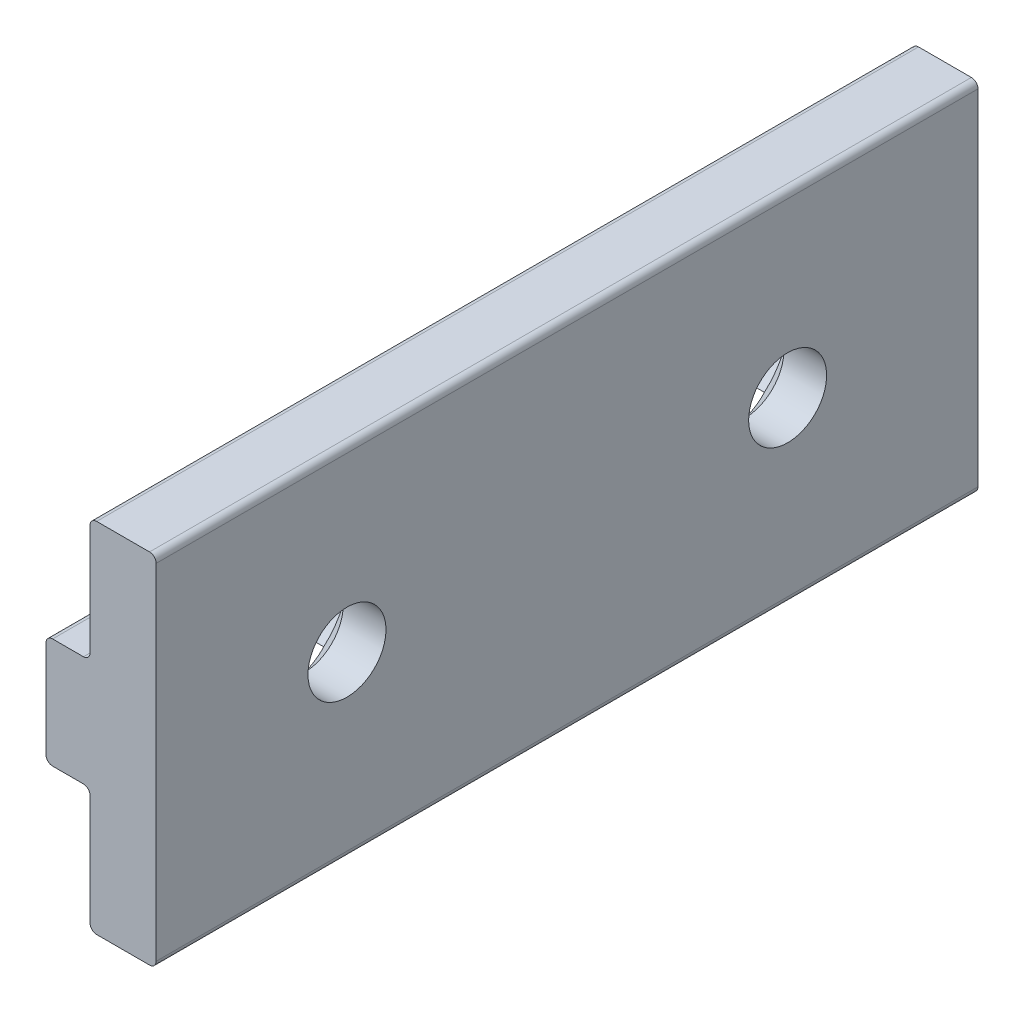
from build123d import *

# Parameters (mm, degrees)
EXTRUDE1_DEPTH                            = 47.371
SKETCH2_R                                 = 1.3843
CUT_EXTRUDE1_DEPTH                        = 7.35
CSK_FOR_8_FLAT_HEAD_MACHINE_SCREW_2_COUNT = 2
CSK_FOR_8_FLAT_HEAD_MACHINE_SCREW_2_PITCH = 25.4


with BuildPart() as part:
    # Sketch1 → Extrude1 (new body)
    with BuildSketch(Plane.XY):
        with BuildLine():
            Line((761.528249985, 570.229723122), (761.528249985, 550.366923122))
            ThreePointArc((761.528249985, 550.366923122), (761.416657669, 550.097515438), (761.147249985, 549.985923122))
            Line((761.147249985, 549.985923122), (758.099249985, 549.985923122))
            ThreePointArc((758.099249985, 549.985923122), (757.829842301, 550.097515438), (757.718249985, 550.366923122))
            Line((757.718249985, 550.366923122), (757.718249985, 556.742323122))
            ThreePointArc((757.718249985, 556.742323122), (757.606657669, 557.011730805), (757.337249985, 557.123323122))
            Line((757.337249985, 557.123323122), (755.559249985, 557.123323122))
            ThreePointArc((755.559249985, 557.123323122), (755.289842301, 557.234915438), (755.178249985, 557.504323122))
            Line((755.178249985, 557.504323122), (755.178249985, 563.092323122))
            ThreePointArc((755.178249985, 563.092323122), (755.289842301, 563.361730805), (755.559249985, 563.473323122))
            Line((755.559249985, 563.473323122), (757.337249985, 563.473323122))
            ThreePointArc((757.337249985, 563.473323122), (757.606657669, 563.584915438), (757.718249985, 563.854323122))
            Line((757.718249985, 563.854323122), (757.718249985, 570.229723122))
            ThreePointArc((757.718249985, 570.229723122), (757.829842301, 570.499130805), (758.099249985, 570.610723122))
            Line((758.099249985, 570.610723122), (761.147249985, 570.610723122))
            ThreePointArc((761.147249985, 570.610723122), (761.416657669, 570.499130805), (761.528249985, 570.229723122))
        make_face()
    extrude(amount=EXTRUDE1_DEPTH)

    # Sketch2 → Cut-Extrude1 (cut, through all)
    with BuildSketch(Plane.ZY.offset(-755.178249985)):
        with Locations((10.9728, 560.298323122)):
            Circle(SKETCH2_R)
        with Locations((36.3728, 560.298323122)):
            Circle(SKETCH2_R)
    extrude(amount=-CUT_EXTRUDE1_DEPTH, mode=Mode.SUBTRACT)

    # Sketch3 → CSK for #8 Flat Head Machine Screw (100)1 (revolve, cut)
    with BuildSketch(Plane(origin=(755.178249985, 560.298323122, 10.9728), x_dir=(0, 0, 1), z_dir=(0, 1, 0))):
        Polygon((0, 0), (0, 6.35), (2.2479, 6.35), (2.2479, 3.886967624), (4.2164, 2.2352), (4.2164, 0), align=None)
    csk_for_8_flat_head_machine_screw_100 = revolve(axis=Axis((748.828249985, 560.298323122, 10.9728), (1, 0, 0)), mode=Mode.SUBTRACT)

    # CSK for _8 Flat Head Machine Screw _ 2: CSK for #8 Flat Head Machine Screw (100)1 ×2
    with Locations(*[(0, 0, i * CSK_FOR_8_FLAT_HEAD_MACHINE_SCREW_2_PITCH) for i in range(1, CSK_FOR_8_FLAT_HEAD_MACHINE_SCREW_2_COUNT)]):
        add(csk_for_8_flat_head_machine_screw_100, mode=Mode.SUBTRACT)


solid = part.part
